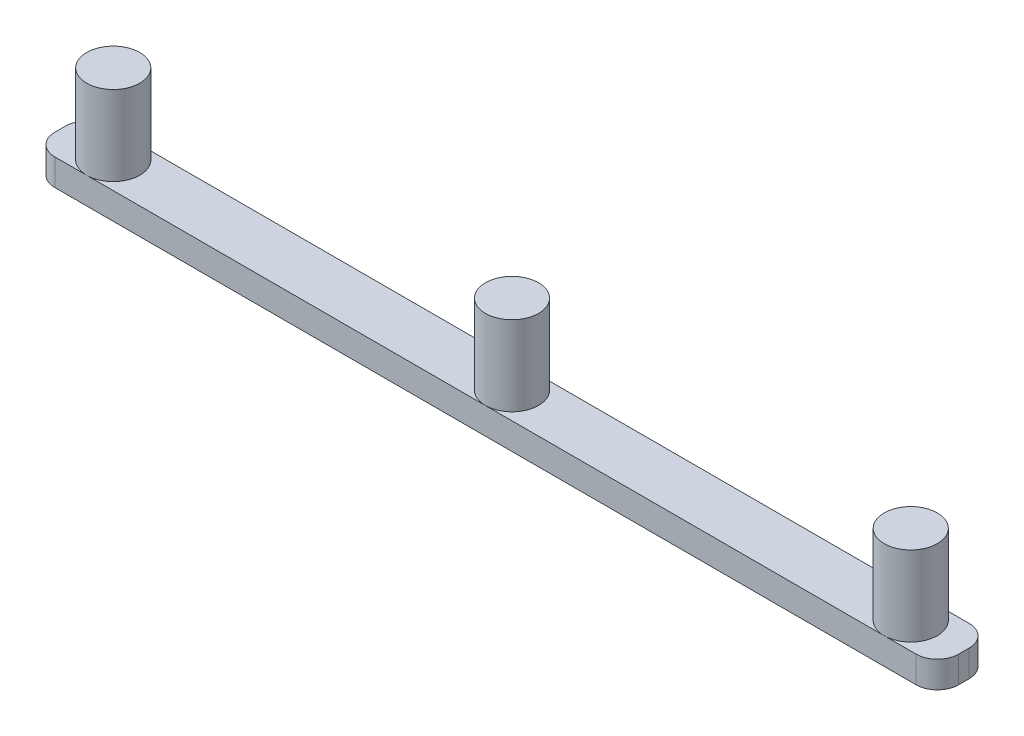
from build123d import *

# Parameters (mm, degrees)
BOSS_EXTRU_1_DEPTH = 5
ESQUISSE2_R        = 5
BOSS_EXTRU_2_DEPTH = 15


with BuildPart() as part:
    # Esquisse1 → Boss.-Extru.1 (new body)
    with BuildSketch(Plane(origin=(0, 0, 0), x_dir=(1, 0, 0), z_dir=(0, 1, 0))):
        with BuildLine():
            Line((-4, 0), (-166, 0))
            ThreePointArc((-166, 0), (-168.828427125, 1.171572875), (-170, 4))
            Line((-170, 4), (-170, 6))
            ThreePointArc((-170, 6), (-168.828427125, 8.828427125), (-166, 10))
            Line((-166, 10), (-4, 10))
            ThreePointArc((-4, 10), (-1.171572875, 8.828427125), (0, 6))
            Line((0, 6), (0, 4))
            ThreePointArc((0, 4), (-1.171572875, 1.171572875), (-4, 0))
        make_face()
    extrude(amount=BOSS_EXTRU_1_DEPTH)

    # Esquisse2 → Boss.-Extru.2 (add)
    with BuildSketch(Plane(origin=(0, 5, 0), x_dir=(1, 0, 0), z_dir=(0, 1, 0))):
        with Locations((-160, 5)):
            Circle(ESQUISSE2_R)
        with Locations((-85, 5)):
            Circle(ESQUISSE2_R)
        with Locations((-10, 5)):
            Circle(ESQUISSE2_R)
    extrude(amount=BOSS_EXTRU_2_DEPTH)


solid = part.part
